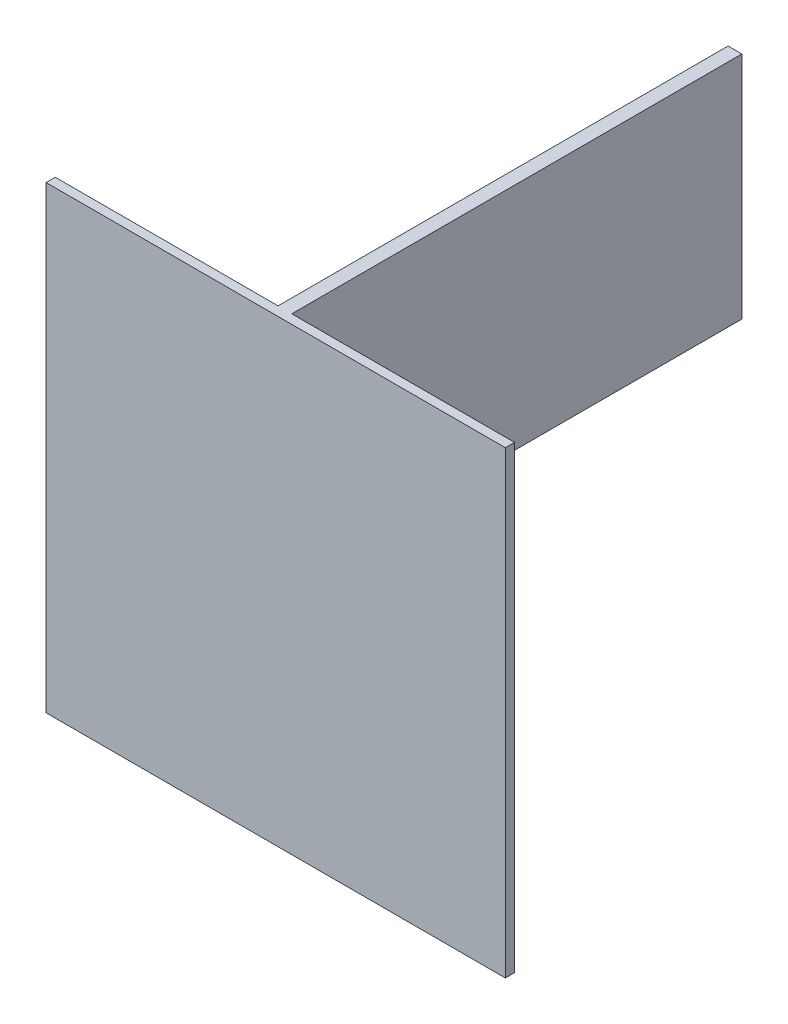
from build123d import *

# Parameters (mm, degrees)
SZKIC1_W                    = 100
SZKIC1_H                    = 100
DODANIE_WYCI_GNI_CIE1_DEPTH = 4
DODANIE_WYCI_GNI_CIE2_DEPTH = 196


with BuildPart() as part:
    # Szkic1 → Dodanie-wyciągnięcie1 (new body)
    with BuildSketch(Plane.XY):
        with Locations((-50, 50)):
            Rectangle(SZKIC1_W, SZKIC1_H)
        with Locations((50, 50)):
            Rectangle(SZKIC1_W, SZKIC1_H)
        with Locations((50, -50)):
            Rectangle(SZKIC1_W, SZKIC1_H)
        with Locations((-50, -50)):
            Rectangle(SZKIC1_W, SZKIC1_H)
    extrude(amount=DODANIE_WYCI_GNI_CIE1_DEPTH)

    # Szkic2 → Dodanie-wyciągnięcie2 (add)
    with BuildSketch(Plane(origin=(0, 0, 0), x_dir=(-1, 0, 0), z_dir=(0, 0, -1))):
        Polygon((0, 0), (3, 0), (3, 100), (-3, 100), (-3, 0), align=None)
    extrude(amount=DODANIE_WYCI_GNI_CIE2_DEPTH)


solid = part.part
